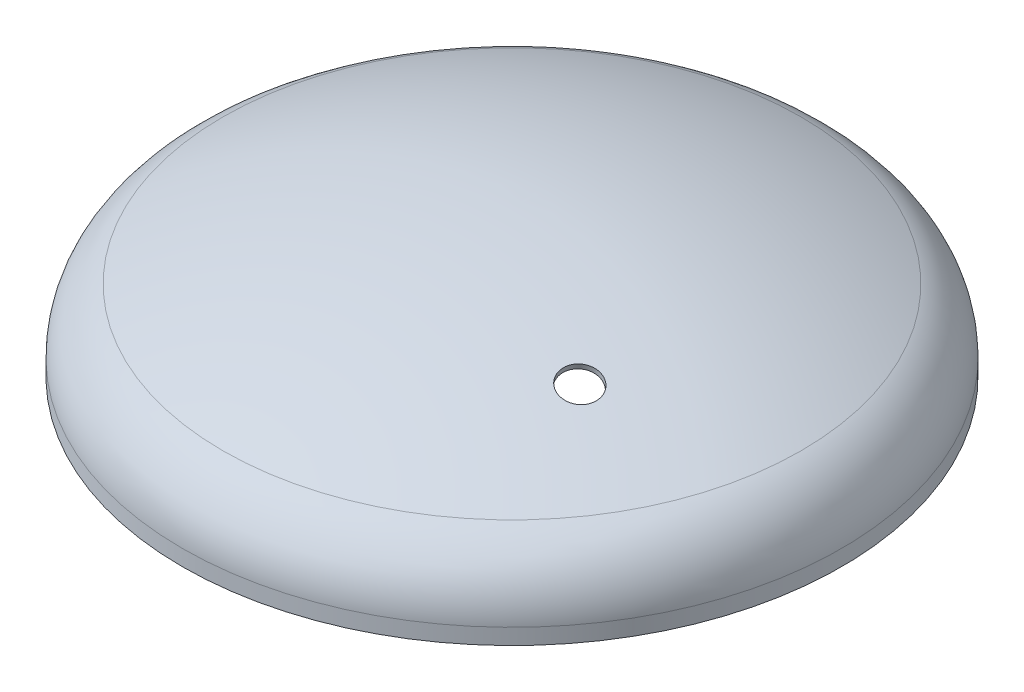
from build123d import *

# Parameters (mm, degrees)
F_20_0_20_DURCHMESSER_BOHRUNG1_D = 20


with BuildPart() as part:
    # Skizze1 → Rotation1 (revolve)
    with BuildSketch(Plane(origin=(0, 0, 0), x_dir=(0, 0, -1), z_dir=(1, 0, 0)), mode=Mode.PRIVATE) as rotation1_sk:
        with BuildLine():
            Line((177.8, 0), (177.8, 8.537744837))
            ThreePointArc((177.8, 8.537744837), (171.896273488, 29.053926256), (155.991, 43.294360308))
            ThreePointArc((155.991, 43.294360308), (80.012631482, 69.959635546), (0, 79))
            Line((0, 79), (0, 76))
            ThreePointArc((0, 76), (79.343256428, 67.035266035), (154.686, 40.593068951))
            ThreePointArc((154.686, 40.593068951), (169.355112336, 27.459404384), (174.8, 8.537744837))
            Line((174.8, 8.537744837), (174.8, 0))
            Line((174.8, 0), (177.8, 0))
        make_face()
    revolve(rotation1_sk.sketch.rotate(Axis((0, 44.907564577, 0), (0, -1, 0)), 180), axis=Axis((0, 44.907564577, 0), (0, -1, 0)))  # turned: the seam where the file's is

    # Ø20.0 (20) Durchmesser Bohrung1 (through all)
    with Locations(Plane(origin=(86.602540378, 64.774737749, 50), x_dir=(0.969804385, -0.243884101, 0), z_dir=(0.241501786, 0.960331115, 0.139431121))):
        with Locations((0, 0)):
            Hole(F_20_0_20_DURCHMESSER_BOHRUNG1_D / 2)


solid = part.part
